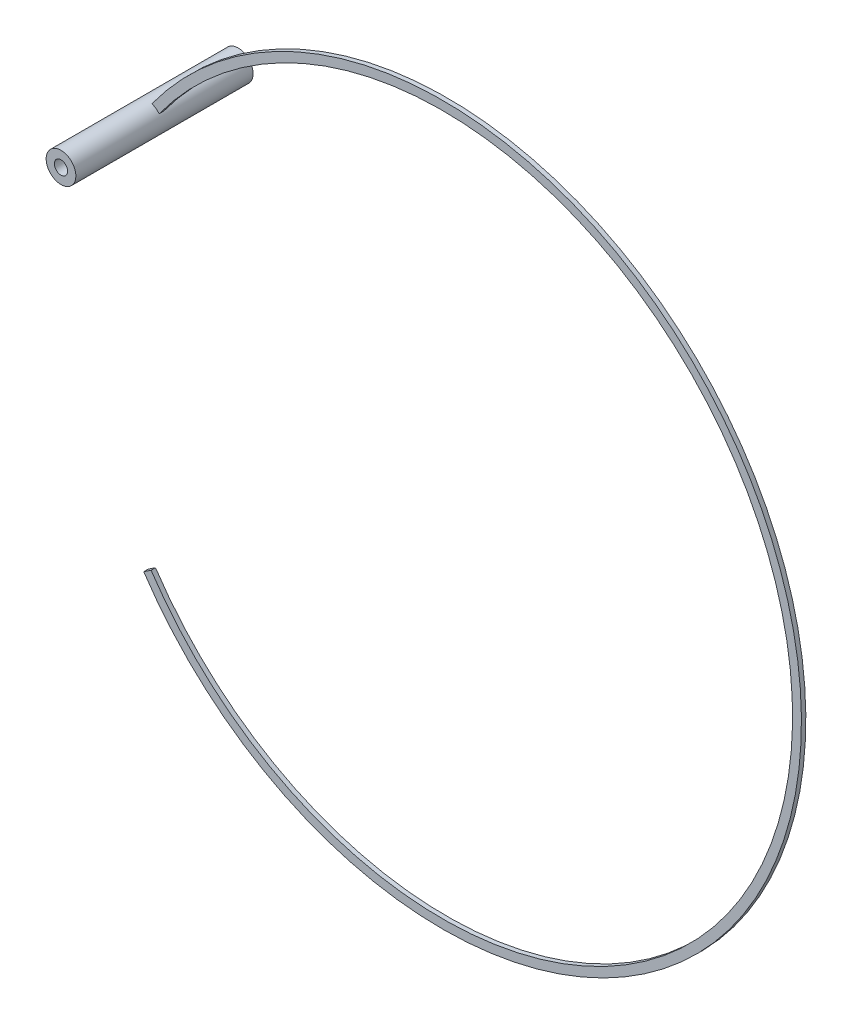
from build123d import *

# Parameters (mm, degrees)
SKETCH1_R           = 1.675263483
SKETCH1_R_2         = 0.75
BOSS_EXTRUDE1_DEPTH = 10
SKETCH3_W           = 0.497124842
SKETCH3_H           = 1


with BuildPart() as part:
    # Sketch1 → Boss-Extrude1 (new body, symmetric)
    with BuildSketch(Plane.XY):
        with Locations((-12.495417101, 27.339793711)):
            Circle(SKETCH1_R)
        with Locations((-12.495417101, 27.339793711)):
            Circle(SKETCH1_R_2, mode=Mode.SUBTRACT)
    extrude(amount=BOSS_EXTRUDE1_DEPTH, both=True)

    # Sweep1: sweep along a path in Sketch2
    with BuildLine(Plane.XY) as sweep1_path:
        ThreePointArc((-12.495417101, 27.339793711), (60.808757123, 5.185065564), (-12.495417101, -16.969662583))
    # Sketch3 → Sweep1 (sweep)
    with BuildSketch(Plane(origin=(-12.495417101, 27.339793711, 0), x_dir=(0, 0, 1), z_dir=(0.553868204, 0.832604356, 0))):
        Rectangle(SKETCH3_W, SKETCH3_H)
    sweep(path=sweep1_path.line)


solid = part.part
